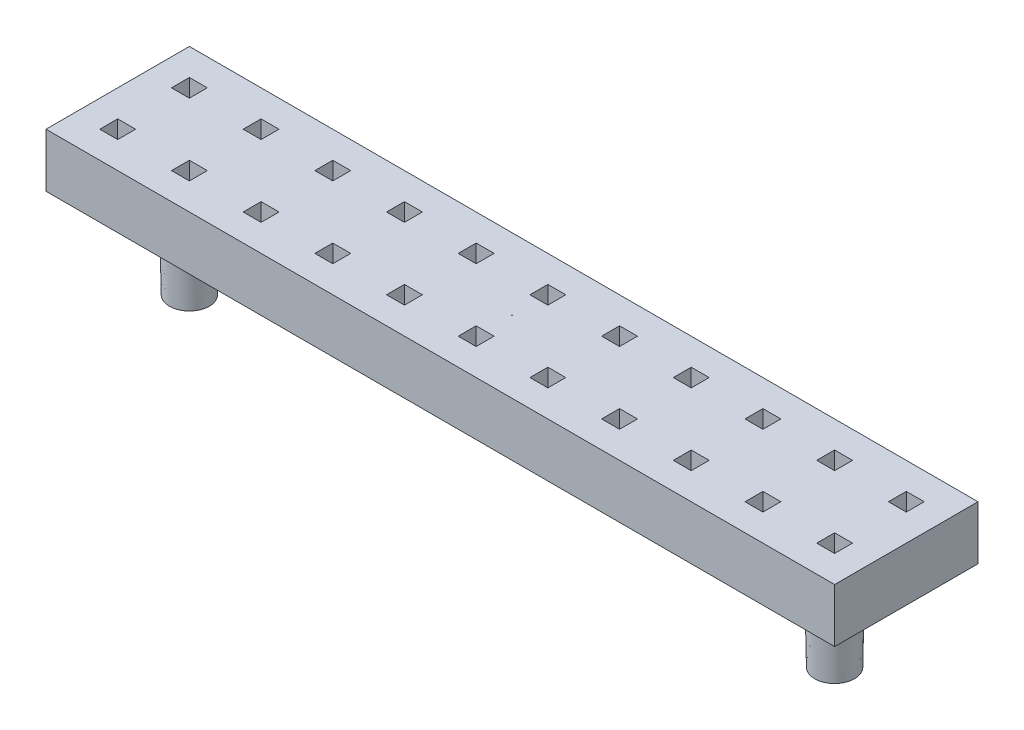
from build123d import *

# Parameters (mm, degrees)
SKETCH1_W                     = 22
SKETCH1_H                     = 4
BOSS_EXTRUDE1_DEPTH           = 1.5
SKETCH2_W                     = 0.5
SKETCH2_H                     = 0.5
CUT_EXTRUDE1_DEPTH            = 2
SKETCH3_R                     = 0.01
CUT_EXTRUDE2_DEPTH            = 1.5
SKETCH4_R                     = 0.6
BOSS_EXTRUDE2_DEPTH           = 2.5
BOSS_EXTRUDE2_DRAFT           = 1
BOSS_EXTRUDE2_PROFILE_2_DEPTH = 2.5
BOSS_EXTRUDE2_PROFILE_2_DRAFT = 1


with BuildPart() as part:
    # Sketch1 → Boss-Extrude1 (new body)
    with BuildSketch(Plane(origin=(0, 0, 0), x_dir=(1, 0, 0), z_dir=(0, 1, 0))):
        with Locations((11, 2)):
            Rectangle(SKETCH1_W, SKETCH1_H)
    extrude(amount=BOSS_EXTRUDE1_DEPTH)

    # Sketch2 → Cut-Extrude1 (cut)
    with BuildSketch(Plane(origin=(0, 1.5, 0), x_dir=(1, 0, 0), z_dir=(0, 1, 0))):
        with Locations((3, 3)):
            Rectangle(SKETCH2_W, SKETCH2_H)
        with Locations((1, 3)):
            Rectangle(SKETCH2_W, SKETCH2_H)
        with Locations((5, 3)):
            Rectangle(SKETCH2_W, SKETCH2_H)
        with Locations((7, 3)):
            Rectangle(SKETCH2_W, SKETCH2_H)
        with Locations((9, 3)):
            Rectangle(SKETCH2_W, SKETCH2_H)
        with Locations((11, 3)):
            Rectangle(SKETCH2_W, SKETCH2_H)
        with Locations((13, 3)):
            Rectangle(SKETCH2_W, SKETCH2_H)
        with Locations((15, 3)):
            Rectangle(SKETCH2_W, SKETCH2_H)
        with Locations((17, 3)):
            Rectangle(SKETCH2_W, SKETCH2_H)
        with Locations((19, 3)):
            Rectangle(SKETCH2_W, SKETCH2_H)
        with Locations((21, 3)):
            Rectangle(SKETCH2_W, SKETCH2_H)
        with Locations((1, 1)):
            Rectangle(SKETCH2_W, SKETCH2_H)
        with Locations((3, 1)):
            Rectangle(SKETCH2_W, SKETCH2_H)
        with Locations((5, 1)):
            Rectangle(SKETCH2_W, SKETCH2_H)
        with Locations((7, 1)):
            Rectangle(SKETCH2_W, SKETCH2_H)
        with Locations((9, 1)):
            Rectangle(SKETCH2_W, SKETCH2_H)
        with Locations((11, 1)):
            Rectangle(SKETCH2_W, SKETCH2_H)
        with Locations((13, 1)):
            Rectangle(SKETCH2_W, SKETCH2_H)
        with Locations((15, 1)):
            Rectangle(SKETCH2_W, SKETCH2_H)
        with Locations((17, 1)):
            Rectangle(SKETCH2_W, SKETCH2_H)
        with Locations((19, 1)):
            Rectangle(SKETCH2_W, SKETCH2_H)
        with Locations((21, 1)):
            Rectangle(SKETCH2_W, SKETCH2_H)
    extrude(amount=-CUT_EXTRUDE1_DEPTH, mode=Mode.SUBTRACT)

    # Sketch3 → Cut-Extrude2 (cut)
    with BuildSketch(Plane(origin=(0, 1.5, 0), x_dir=(1, 0, 0), z_dir=(0, 1, 0))):
        with Locations((11, 2)):
            Circle(SKETCH3_R)
    extrude(amount=-CUT_EXTRUDE2_DEPTH, mode=Mode.SUBTRACT)


with BuildPart() as boss_extrude2_tool:
    # Sketch4 → Boss-Extrude2 (with draft: the straight prism first)
    with BuildSketch(Plane(origin=(0, 0, 0), x_dir=(-1, 0, 0), z_dir=(0, -1, 0))):
        with Locations((-20, 2)):
            Circle(SKETCH4_R)
    extrude(amount=BOSS_EXTRUDE2_DEPTH)
    # Boss-Extrude2: the draft: its side faces are tilted about the plane it starts from
    boss_extrude2_sides = [boss_extrude2_tool.faces().sort_by_distance(p)[0] for p in [
        (20.6, -1.25, -2),
    ]]
    draft(boss_extrude2_sides, Plane(origin=(0, 0, 0), x_dir=(-1, 0, 0), z_dir=(0, -1, 0)), BOSS_EXTRUDE2_DRAFT)


with BuildPart() as part_1:
    add(part.part)

    # Boss-Extrude2: add boss_extrude2_tool
    add(boss_extrude2_tool.part)


with BuildPart() as boss_extrude2_profile_2_tool:
    # Sketch4 → Boss-Extrude2 profile 2 (with draft: the straight prism first)
    with BuildSketch(Plane(origin=(0, 0, 0), x_dir=(-1, 0, 0), z_dir=(0, -1, 0))):
        with Locations((-2, 2)):
            Circle(SKETCH4_R)
    extrude(amount=BOSS_EXTRUDE2_PROFILE_2_DEPTH)
    # Boss-Extrude2 profile 2: the draft: its side faces are tilted about the plane it starts from
    boss_extrude2_profile_2_sides = [boss_extrude2_profile_2_tool.faces().sort_by_distance(p)[0] for p in [
        (2.6, -1.25, -2),
    ]]
    draft(boss_extrude2_profile_2_sides, Plane(origin=(0, 0, 0), x_dir=(-1, 0, 0), z_dir=(0, -1, 0)), BOSS_EXTRUDE2_PROFILE_2_DRAFT)


with BuildPart() as part_2:
    add(part_1.part)

    # Boss-Extrude2 profile 2: add boss_extrude2_profile_2_tool
    add(boss_extrude2_profile_2_tool.part)


solid = part_2.part
